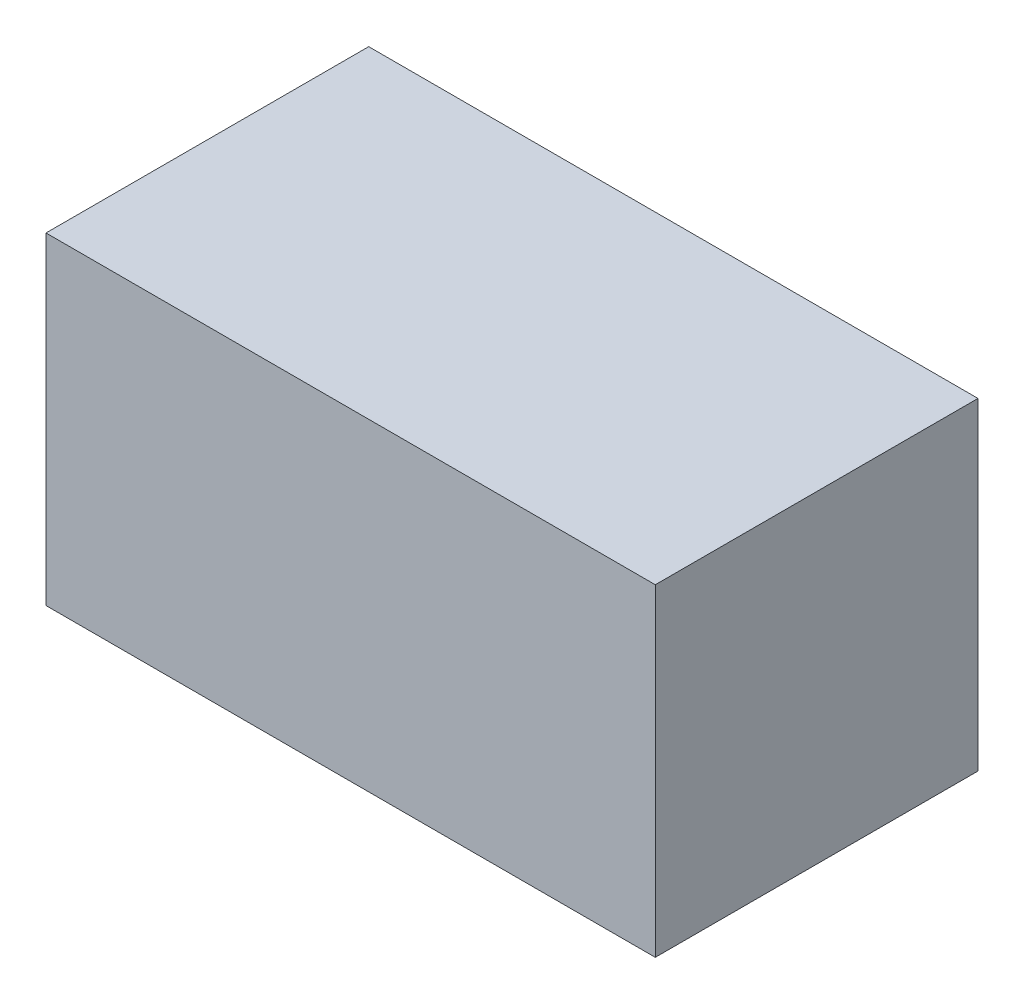
from build123d import *

# Parameters (mm, degrees)
SKETCH1_W           = 1.8161
SKETCH1_H           = 1.8161
BOSS_EXTRUDE1_DEPTH = 1.7145


with BuildPart() as part:
    # Sketch1 → Boss-Extrude1 (new body, symmetric)
    with BuildSketch(Plane(origin=(0, 0, 0), x_dir=(0, 0, -1), z_dir=(1, 0, 0))):
        with Locations((0, 0.90805)):
            Rectangle(SKETCH1_W, SKETCH1_H)
    extrude(amount=BOSS_EXTRUDE1_DEPTH, both=True)


solid = part.part
